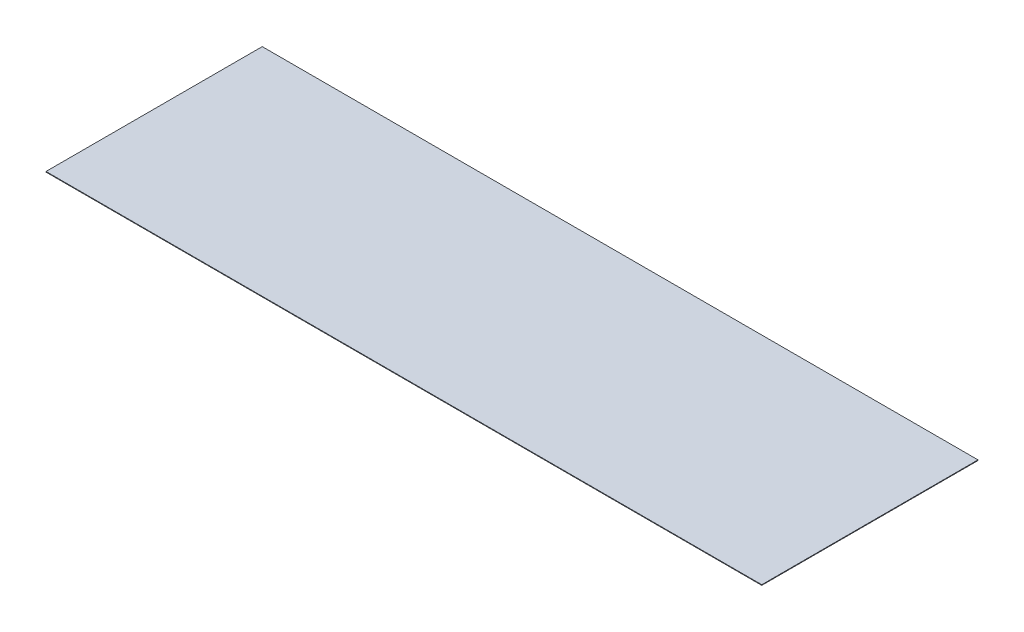
from build123d import *

# Parameters (mm, degrees)
SKETCH1_W           = 30480
SKETCH1_H           = 9207.5
BOSS_EXTRUDE1_DEPTH = 25.4


with BuildPart() as part:
    # Sketch1 → Boss-Extrude1 (new body)
    with BuildSketch(Plane(origin=(0, 0, 0), x_dir=(1, 0, 0), z_dir=(0, 1, 0))):
        Rectangle(SKETCH1_W, SKETCH1_H)
    extrude(amount=BOSS_EXTRUDE1_DEPTH)


solid = part.part
